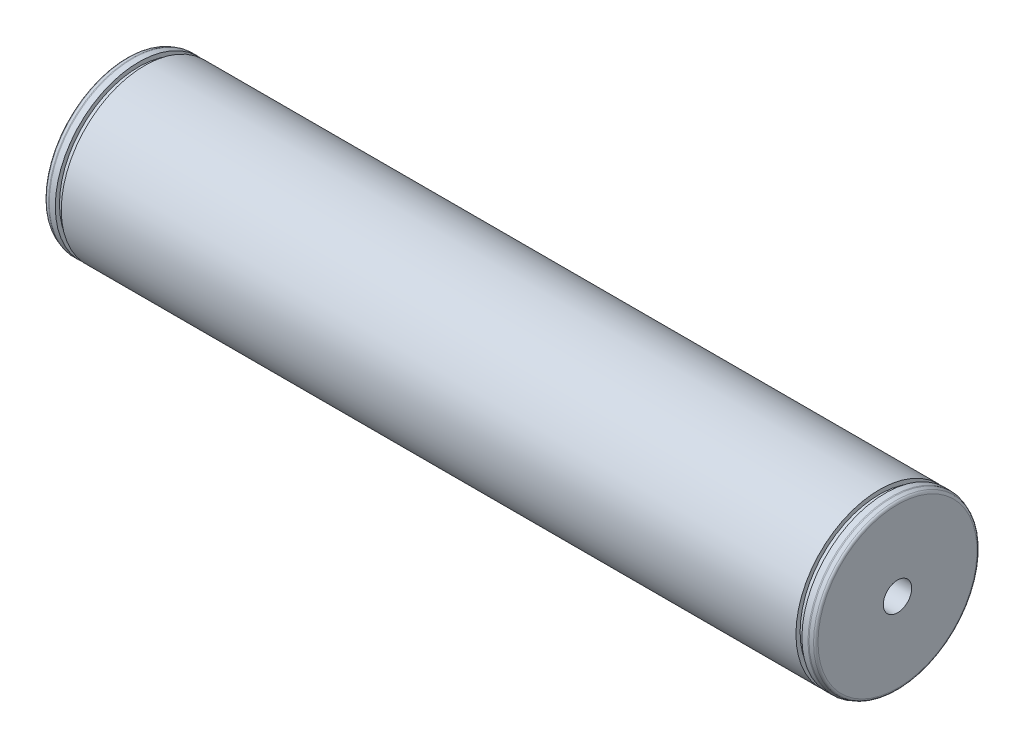
from build123d import *


with BuildPart() as part:
    # Sketch1 → Base-Revolve (revolve)
    with BuildSketch(Plane.XY):
        with BuildLine():
            Line((132, 30), (0, 30))
            Line((0, 30), (-132, 30))
            Line((-132, 30), (-132, 28.5))
            Line((-132, 28.5), (-134.15, 28.5))
            Line((-134.15, 28.5), (-134.15, 30))
            Line((-134.15, 30), (-136.323673019, 30))
            ThreePointArc((-136.323673019, 30), (-136.497321197, 29.984807753), (-136.665693163, 29.939692621))
            Line((-136.665693163, 29.939692621), (-137.842020143, 29.511544614))
            ThreePointArc((-137.842020143, 29.511544614), (-138.319152044, 29.14542843), (-138.5, 28.571851993))
            Line((-138.5, 28.571851993), (-138.5, 0))
            Line((-138.5, 0), (115.555513627, 0))
            Line((115.555513627, 0), (118.5, 5.1))
            Line((118.5, 5.1), (138.5, 5.1))
            Line((138.5, 5.1), (138.5, 28.571851993))
            ThreePointArc((138.5, 28.571851993), (138.319152044, 29.14542843), (137.842020143, 29.511544614))
            Line((137.842020143, 29.511544614), (136.665693163, 29.939692621))
            ThreePointArc((136.665693163, 29.939692621), (136.497321197, 29.984807753), (136.323673019, 30))
            Line((136.323673019, 30), (134.15, 30))
            Line((134.15, 30), (134.15, 28.5))
            Line((134.15, 28.5), (132, 28.5))
            Line((132, 28.5), (132, 30))
        make_face()
    revolve(axis=Axis((-138.5, 0, 0), (1, 0, 0)))


solid = part.part
